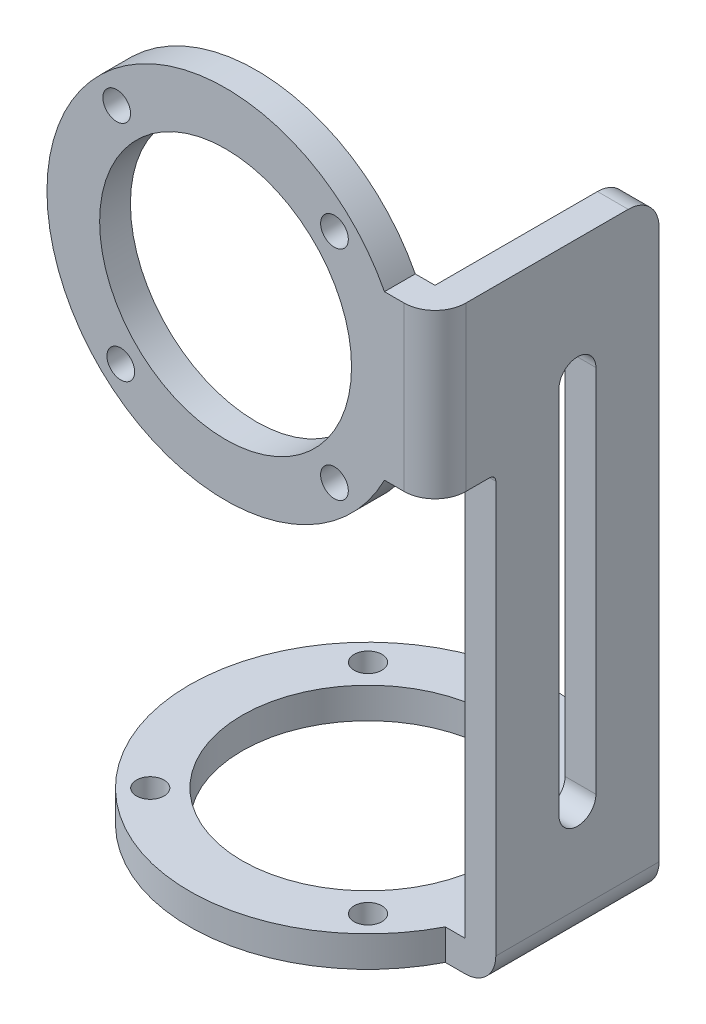
from build123d import *

# Parameters (mm, degrees)
SKETCH1_R           = 20.45
BOSS_EXTRUDE2_DEPTH = 5
BOSS_EXTRUDE3_DEPTH = 5
SKETCH14_R          = 20.45
BOSS_EXTRUDE6_DEPTH = 5
CUT_EXTRUDE2_DEPTH  = 5
BOSS_EXTRUDE7_DEPTH = 26.5
BOSS_EXTRUDE8_DEPTH = 26.5
CUT_EXTRUDE3_DEPTH  = 26.5
SKETCH24_R          = 2.25
CUT_EXTRUDE5_DEPTH  = 10
SKETCH25_R          = 2.25
CUT_EXTRUDE6_DEPTH  = 10


with BuildPart() as part:
    # Sketch1 → Boss-Extrude2 (new body)
    with BuildSketch(Plane.XY):
        with BuildLine():
            Line((29, 13.25), (25.796075283, 13.25))
            ThreePointArc((25.796075283, 13.25), (-29, 0), (25.796075283, -13.25))
            Line((25.796075283, -13.25), (29, -13.25))
            Line((29, -13.25), (29, 13.25))
        make_face()
        Circle(SKETCH1_R, mode=Mode.SUBTRACT)
    extrude(amount=BOSS_EXTRUDE2_DEPTH)



with BuildPart() as body_2:
    # Sketch2 → Boss-Extrude3 (new body)
    with BuildSketch(Plane(origin=(29, 0, 0), x_dir=(0, 0, -1), z_dir=(1, 0, 0))):
        with BuildLine():
            Line((0, 13.25), (26.375, 13.25))
            ThreePointArc((26.375, 13.25), (29.910533906, 11.785533906), (31.375, 8.25))
            Line((31.375, 8.25), (31.375, -81))
            Line((31.375, -81), (0, -81))
            Line((0, -81), (0, -13.25))
            Line((0, -13.25), (0, 13.25))
        make_face()
    extrude(amount=BOSS_EXTRUDE3_DEPTH)

    # Sketch17 → Cut-Extrude2 (cut)
    with BuildSketch(Plane(origin=(34, 0, 0), x_dir=(0, 0, -1), z_dir=(1, 0, 0))):
        with BuildLine():
            Line((0, -13.25), (3.875, -13.25))
            ThreePointArc((3.875, -13.25), (4.582106781, -13.542893219), (4.875, -14.25))
            Line((4.875, -14.25), (4.875, -81))
            Line((4.875, -81), (0, -81))
            Line((0, -81), (0, -13.25))
        make_face()
    extrude(amount=-CUT_EXTRUDE2_DEPTH, mode=Mode.SUBTRACT)


with BuildPart() as body_3:
    # Sketch14 → Boss-Extrude6 (new body)
    with BuildSketch(Plane.XZ.offset(81)):
        with BuildLine():
            Line((29, -4.875), (25.796075283, -4.875))
            ThreePointArc((25.796075283, -4.875), (-29, -18.125), (25.796075283, -31.375))
            Line((25.796075283, -31.375), (29, -31.375))
            Line((29, -31.375), (29, -4.875))
        make_face()
        with Locations(Location((0, -18.125, 0), (0, 0, 270))):
            Circle(SKETCH14_R, mode=Mode.SUBTRACT)
    extrude(amount=BOSS_EXTRUDE6_DEPTH)


with BuildPart() as part_1:
    add(part.part)

    add(body_2.part)  # Boss-Extrude7 merges body 2
    # Sketch21 → Boss-Extrude7 (add)
    with BuildSketch(Plane(origin=(0, 13.25, 0), x_dir=(1, 0, 0), z_dir=(0, 1, 0))):
        with BuildLine():
            Line((29, 0), (29, -5))
            ThreePointArc((29, -5), (32.535533906, -3.535533906), (34, 0))
            Line((34, 0), (29, 0))
        make_face()
    extrude(amount=-BOSS_EXTRUDE7_DEPTH)


    add(body_3.part)  # Boss-Extrude8 merges body 3
    # Sketch22 → Boss-Extrude8 (add)
    with BuildSketch(Plane.XY.offset(-4.875)):
        with BuildLine():
            ThreePointArc((29, -86), (32.535533906, -84.535533906), (34, -81))
            Line((34, -81), (29, -81))
            Line((29, -81), (29, -86))
        make_face()
    extrude(amount=-BOSS_EXTRUDE8_DEPTH)

    # Sketch23 → Cut-Extrude3 (cut)
    with BuildSketch(Plane(origin=(34, 0, 0), x_dir=(0, 0, -1), z_dir=(1, 0, 0))):
        with BuildLine():
            Line((15.125, -6.375), (15.125, -36.375))
            Line((15.125, -36.375), (18.125, -36.375))
            Line((18.125, -36.375), (21.125, -36.375))
            Line((21.125, -36.375), (21.125, -6.375))
            ThreePointArc((21.125, -6.375), (18.125, -3.375), (15.125, -6.375))
        make_face()
        with BuildLine():
            Line((21.125, -36.375), (18.125, -36.375))
            Line((18.125, -36.375), (18.125, -69.375))
            ThreePointArc((18.125, -69.375), (20.246320344, -68.496320344), (21.125, -66.375))
            Line((21.125, -66.375), (21.125, -36.375))
        make_face()
        with BuildLine():
            Line((18.125, -36.375), (15.125, -36.375))
            Line((15.125, -36.375), (15.125, -66.375))
            ThreePointArc((15.125, -66.375), (16.003679656, -68.496320344), (18.125, -69.375))
            Line((18.125, -69.375), (18.125, -36.375))
        make_face()
    extrude(amount=-CUT_EXTRUDE3_DEPTH, mode=Mode.SUBTRACT)

    # Sketch24 → Cut-Extrude5 (cut)
    with BuildSketch(Plane.XY.offset(5)):
        with Locations((17.67766953, 17.67766953)):
            Circle(SKETCH24_R)
        with Locations((17.67766953, -17.67766953)):
            Circle(SKETCH24_R)
        with Locations((-17.67766953, 17.67766953)):
            Circle(SKETCH24_R)
        with Locations((-17.01531967, -18.316083002)):
            Circle(SKETCH24_R)
    extrude(amount=-CUT_EXTRUDE5_DEPTH, mode=Mode.SUBTRACT)

    # Sketch25 → Cut-Extrude6 (cut)
    with BuildSketch(Plane.XZ.offset(86)):
        with Locations(Location((-17.67766953, -0.44733047, 0), (0, 0, 270))):
            Circle(SKETCH25_R)
        with Locations(Location((17.67766953, -0.44733047, 0), (0, 0, 270))):
            Circle(SKETCH25_R)
        with Locations(Location((17.67766953, -35.80266953, 0), (0, 0, 270))):
            Circle(SKETCH25_R)
        with Locations(Location((-17.67766953, -35.80266953, 0), (0, 0, 270))):
            Circle(SKETCH25_R)
    extrude(amount=-CUT_EXTRUDE6_DEPTH, mode=Mode.SUBTRACT)


solid = part_1.part
